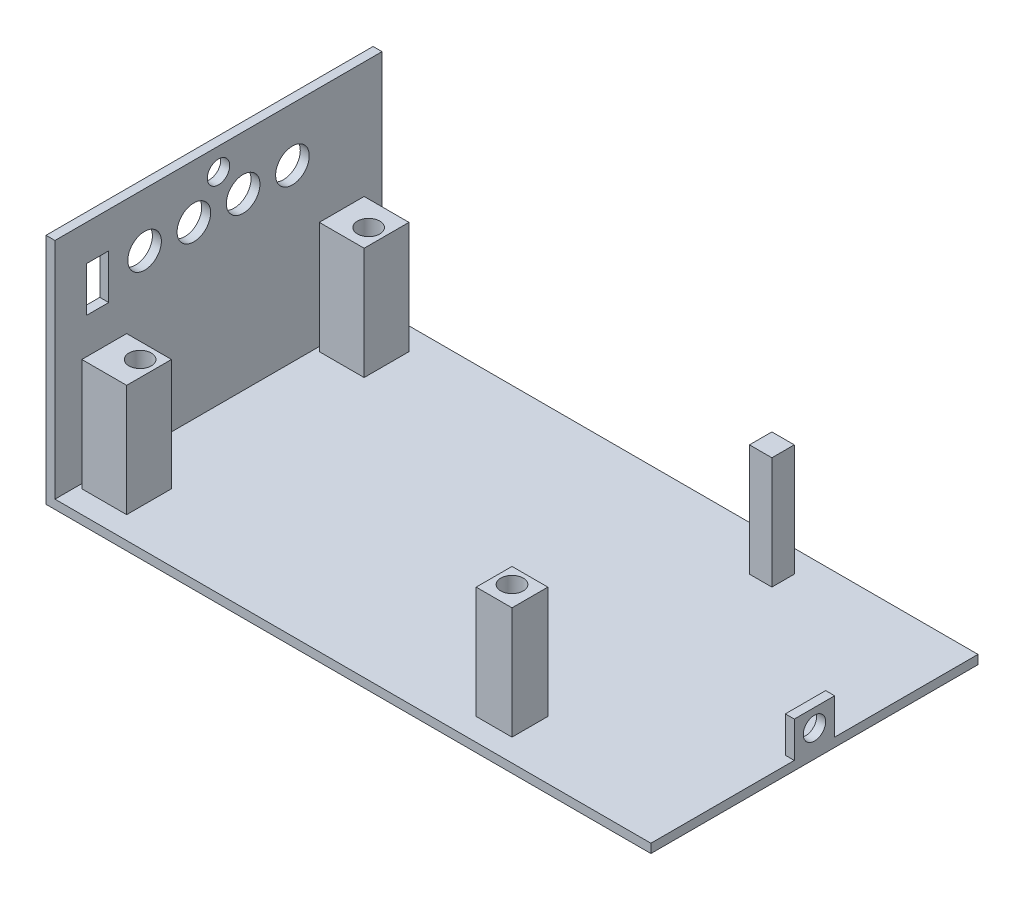
from build123d import *

# Parameters (mm, degrees)
SKETCH1_W           = 135
SKETCH1_H           = 73
BOSS_EXTRUDE1_DEPTH = 2
SKETCH2_W           = 2
SKETCH2_H           = 73
BOSS_EXTRUDE2_DEPTH = 50
SKETCH4_W           = 8
SKETCH4_H           = 8
SKETCH4_R           = 2.5
SKETCH4_W_2         = 10
SKETCH4_H_2         = 10
SKETCH4_W_3         = 5
SKETCH4_H_3         = 5
BOSS_EXTRUDE4_DEPTH = 25
SKETCH5_R           = 2.5
CUT_EXTRUDE1_DEPTH  = 2
SKETCH6_R           = 3.75
CUT_EXTRUDE2_DEPTH  = 2
SKETCH7_W           = 5
SKETCH7_H           = 10
CUT_EXTRUDE3_DEPTH  = 2
SKETCH8_W           = 2
SKETCH8_H           = 9
BOSS_EXTRUDE5_DEPTH = 8
SKETCH9_R           = 2.5
CUT_EXTRUDE4_DEPTH  = 8
SKETCH10_R          = 2.5
CUT_EXTRUDE5_DEPTH  = 2


with BuildPart() as part:
    # Sketch1 → Boss-Extrude1 (new body)
    with BuildSketch(Plane(origin=(0, 0, 0), x_dir=(1, 0, 0), z_dir=(0, 1, 0))):
        Rectangle(SKETCH1_W, SKETCH1_H)
    extrude(amount=BOSS_EXTRUDE1_DEPTH)

    # Sketch2 → Boss-Extrude2 (add)
    with BuildSketch(Plane(origin=(0, 2, 0), x_dir=(1, 0, 0), z_dir=(0, 1, 0))):
        with Locations((-66.5, 0)):
            Rectangle(SKETCH2_W, SKETCH2_H)
    extrude(amount=BOSS_EXTRUDE2_DEPTH)

    # Sketch4 → Boss-Extrude4 (add)
    with BuildSketch(Plane(origin=(0, 2, 0), x_dir=(1, 0, 0), z_dir=(0, 1, 0))):
        with Locations((27.5, -27.5)):
            Rectangle(SKETCH4_W, SKETCH4_H)
        with Locations((27, -27)):
            Circle(SKETCH4_R, mode=Mode.SUBTRACT)
        with Locations((-59.5, -26.5)):
            Rectangle(SKETCH4_W_2, SKETCH4_H_2)
        with Locations((-58, -25)):
            Circle(SKETCH4_R, mode=Mode.SUBTRACT)
        with Locations((-59.5, 26.5)):
            Rectangle(SKETCH4_W_2, SKETCH4_H_2)
        with Locations((-58, 26)):
            Circle(SKETCH4_R, mode=Mode.SUBTRACT)
        with Locations((29, 29)):
            Rectangle(SKETCH4_W_3, SKETCH4_H_3)
    extrude(amount=BOSS_EXTRUDE4_DEPTH)

    # Sketch5 → Cut-Extrude1 (cut)
    with BuildSketch(Plane(origin=(0, 2, 0), x_dir=(1, 0, 0), z_dir=(0, 1, 0))):
        with Locations((9.5, -13.5)):
            Circle(SKETCH5_R)
    extrude(amount=-CUT_EXTRUDE1_DEPTH, mode=Mode.SUBTRACT)

    # Sketch6 → Cut-Extrude2 (cut)
    with BuildSketch(Plane(origin=(-65.5, 0, 0), x_dir=(0, 0, -1), z_dir=(1, 0, 0))):
        with Locations((-16.5, 40)):
            Circle(SKETCH6_R)
        with Locations((-5.5, 40)):
            Circle(SKETCH6_R)
        with Locations((5.5, 40)):
            Circle(SKETCH6_R)
        with Locations((16.5, 40)):
            Circle(SKETCH6_R)
    extrude(amount=-CUT_EXTRUDE2_DEPTH, mode=Mode.SUBTRACT)

    # Sketch7 → Cut-Extrude3 (cut)
    with BuildSketch(Plane(origin=(-65.5, 0, 0), x_dir=(0, 0, -1), z_dir=(1, 0, 0))):
        with Locations((-27, 39)):
            Rectangle(SKETCH7_W, SKETCH7_H)
    extrude(amount=-CUT_EXTRUDE3_DEPTH, mode=Mode.SUBTRACT)

    # Sketch8 → Boss-Extrude5 (add)
    with BuildSketch(Plane(origin=(0, 2, 0), x_dir=(1, 0, 0), z_dir=(0, 1, 0))):
        with Locations((66.5, 0)):
            Rectangle(SKETCH8_W, SKETCH8_H)
    extrude(amount=BOSS_EXTRUDE5_DEPTH)

    # Sketch9 → Cut-Extrude4 (cut)
    with BuildSketch(Plane(origin=(67.5, 0, 0), x_dir=(0, 0, -1), z_dir=(1, 0, 0))):
        with Locations((0, 6)):
            Circle(SKETCH9_R)
    extrude(amount=-CUT_EXTRUDE4_DEPTH, mode=Mode.SUBTRACT)

    # Sketch10 → Cut-Extrude5 (cut)
    with BuildSketch(Plane.ZY.offset(67.5)):
        with Locations((0, 47)):
            Circle(SKETCH10_R)
    extrude(amount=-CUT_EXTRUDE5_DEPTH, mode=Mode.SUBTRACT)


solid = part.part
